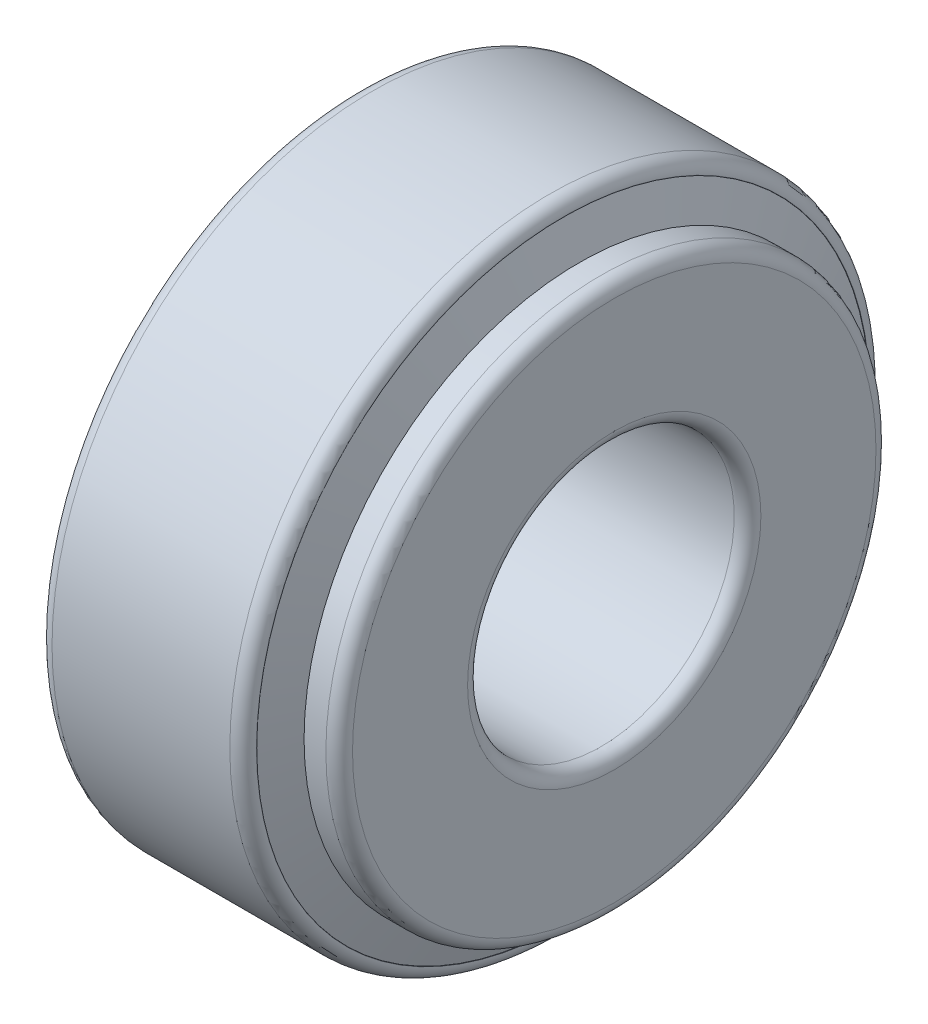
from build123d import *


with BuildPart() as part:
    # Эскиз1 → Повернуть1 (revolve)
    with BuildSketch(Plane.XY):
        with BuildLine():
            Line((3.108893906, 26.504069672), (0, 25.259))
            Line((0, 25.259), (0, 34.5))
            ThreePointArc((0, 34.5), (0.439339828, 35.560660172), (1.5, 36))
            Line((1.5, 36), (21.5, 36))
            ThreePointArc((21.5, 36), (22.560660172, 35.560660172), (23, 34.5))
            Line((23, 34.5), (23, 34.470186779))
            Line((23, 34.470186779), (22.972323763, 34.459102823))
            Line((22.972323763, 34.459102823), (24.79745462, 29.444597006))
            Line((24.79745462, 29.444597006), (24.79745462, 30.944597006))
            Line((24.79745462, 30.944597006), (27.25, 30.944597006))
            ThreePointArc((27.25, 30.944597006), (28.310660172, 30.505257178), (28.75, 29.444597006))
            Line((28.75, 29.444597006), (28.75, 16.5))
            ThreePointArc((28.75, 16.5), (28.310660172, 15.439339828), (27.25, 15))
            Line((27.25, 15), (3.25, 15))
            ThreePointArc((3.25, 15), (2.189339828, 15.439339828), (1.75, 16.5))
            Line((1.75, 16.5), (1.75, 22.770539349))
            Line((1.75, 22.770539349), (4.467787812, 22.770539349))
            Line((4.467787812, 22.770539349), (3.108893906, 26.504069672))
        make_face()
    revolve(axis=Axis((-882.527700014, 0, 0), (1, 0, 0)))


solid = part.part
